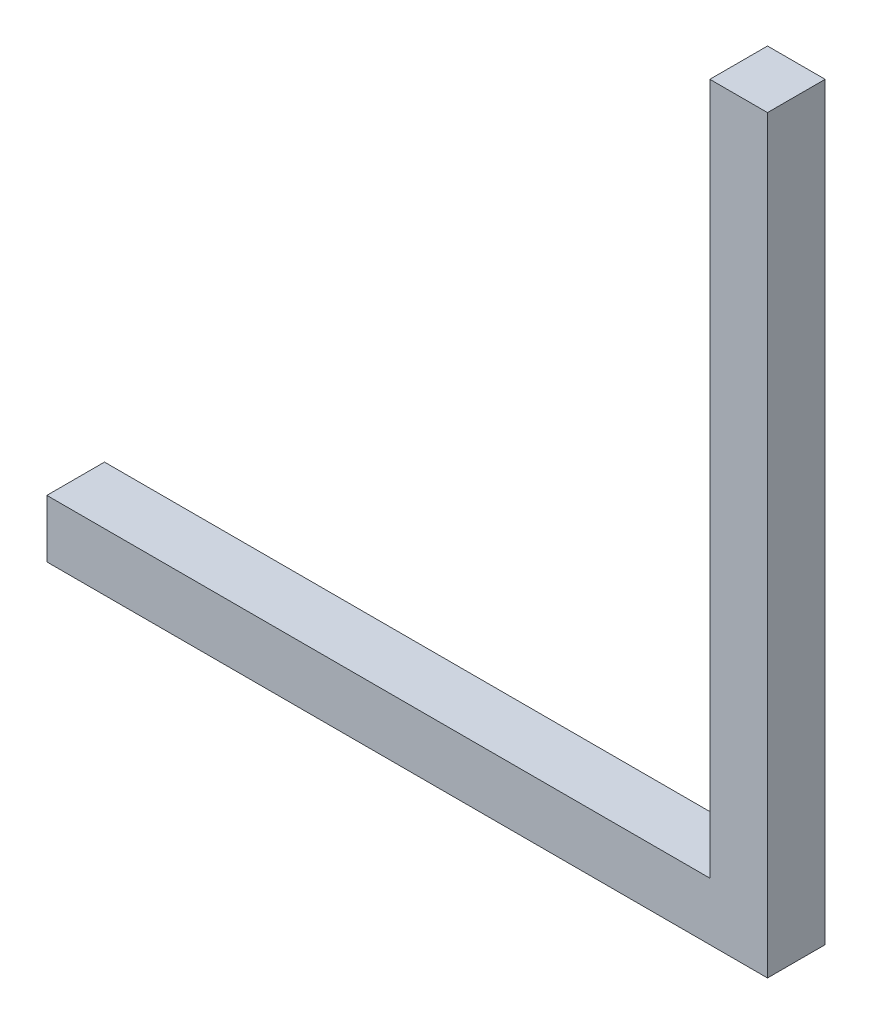
from build123d import *

# Parameters (mm, degrees)
ESQUISSE1_W        = 115
ESQUISSE1_H        = 10
BOSS_EXTRU_1_DEPTH = 10
ESQUISSE2_W        = 10
ESQUISSE2_H        = 130
BOSS_EXTRU_2_DEPTH = 10


with BuildPart() as part:
    # Esquisse1 → Boss.-Extru.1 (new body)
    with BuildSketch(Plane.XY):
        with Locations((39.062768353, 9.317091479)):
            Rectangle(ESQUISSE1_W, ESQUISSE1_H)
    extrude(amount=BOSS_EXTRU_1_DEPTH)

    # Esquisse2 → Boss.-Extru.2 (add)
    with BuildSketch(Plane(origin=(96.562768353, 0, 0), x_dir=(0, 0, -1), z_dir=(1, 0, 0))):
        with Locations((-5, 69.317091479)):
            Rectangle(ESQUISSE2_W, ESQUISSE2_H)
    extrude(amount=BOSS_EXTRU_2_DEPTH)


solid = part.part
